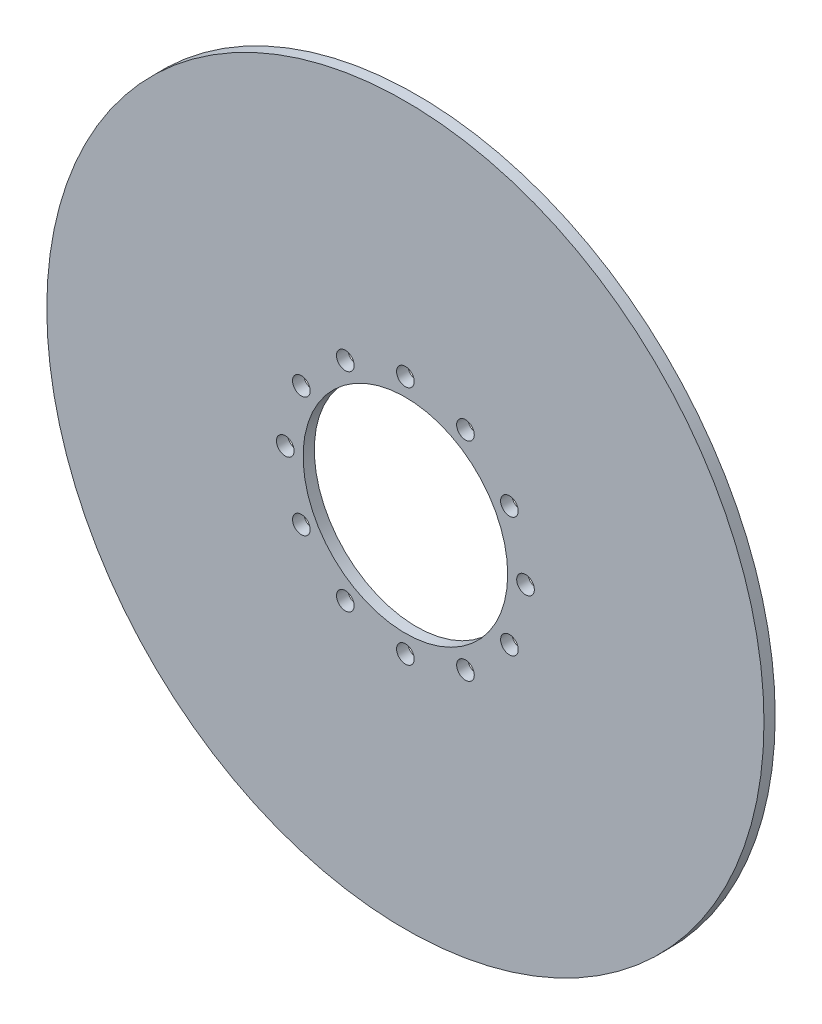
from build123d import *

# Parameters (mm, degrees)
SKETCH1_R           = 101.5
SKETCH1_R_2         = 28.956
SKETCH1_R_3         = 2.49698907
BOSS_EXTRUDE1_DEPTH = 3.175


with BuildPart() as part:
    # Sketch1 → Boss-Extrude1 (new body)
    with BuildSketch(Plane.XY):
        Circle(SKETCH1_R)
        Circle(SKETCH1_R_2, mode=Mode.SUBTRACT)
        with Locations((0, 34)):
            Circle(SKETCH1_R_3, mode=Mode.SUBTRACT)
        with Locations((17, 29.444863729)):
            Circle(SKETCH1_R_3, mode=Mode.SUBTRACT)
        with Locations((29.444863729, 17)):
            Circle(SKETCH1_R_3, mode=Mode.SUBTRACT)
        with Locations((34, 0)):
            Circle(SKETCH1_R_3, mode=Mode.SUBTRACT)
        with Locations((29.444863729, -17)):
            Circle(SKETCH1_R_3, mode=Mode.SUBTRACT)
        with Locations((17, -29.444863729)):
            Circle(SKETCH1_R_3, mode=Mode.SUBTRACT)
        with Locations((0, -34)):
            Circle(SKETCH1_R_3, mode=Mode.SUBTRACT)
        with Locations((-17, -29.444863729)):
            Circle(SKETCH1_R_3, mode=Mode.SUBTRACT)
        with Locations((-29.444863729, -17)):
            Circle(SKETCH1_R_3, mode=Mode.SUBTRACT)
        with Locations((-34, 0)):
            Circle(SKETCH1_R_3, mode=Mode.SUBTRACT)
        with Locations((-29.444863729, 17)):
            Circle(SKETCH1_R_3, mode=Mode.SUBTRACT)
        with Locations((-17, 29.444863729)):
            Circle(SKETCH1_R_3, mode=Mode.SUBTRACT)
    extrude(amount=BOSS_EXTRUDE1_DEPTH)


solid = part.part
